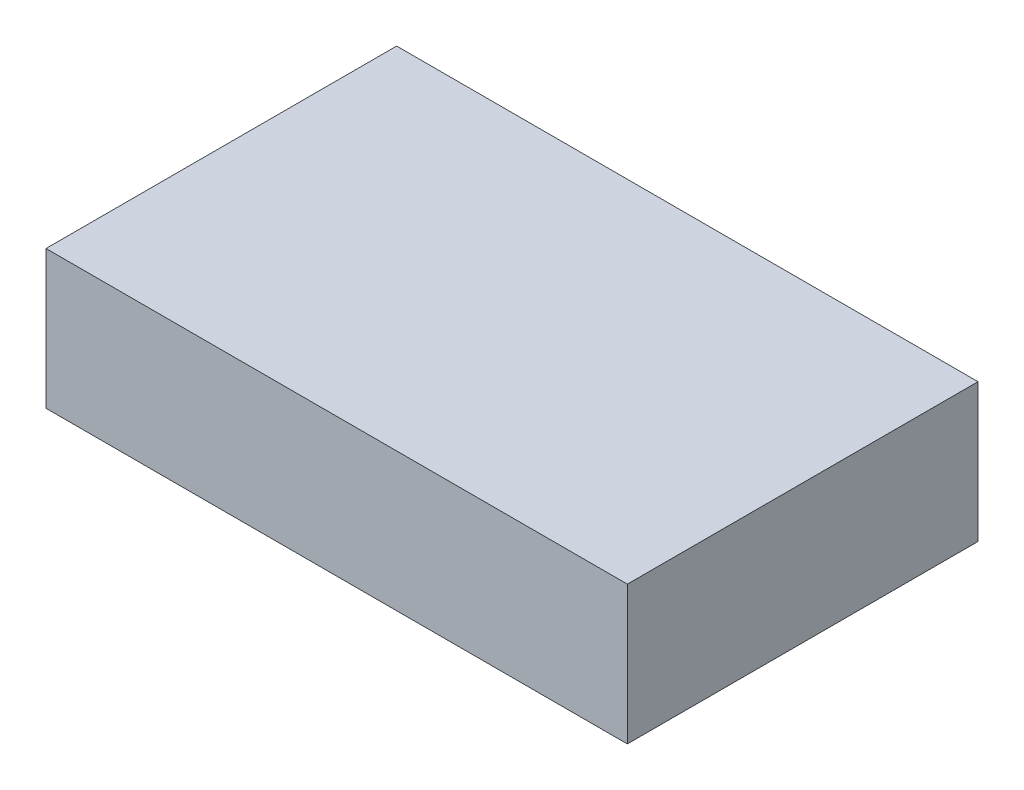
from build123d import *

# Parameters (mm, degrees)
SKETCH1_W           = 160.02
SKETCH1_H           = 96.52
BOSS_EXTRUDE1_DEPTH = 38.1


with BuildPart() as part:
    # Sketch1 → Boss-Extrude1 (new body)
    with BuildSketch(Plane(origin=(0, 0, 0), x_dir=(1, 0, 0), z_dir=(0, 1, 0))):
        Rectangle(SKETCH1_W, SKETCH1_H)
    extrude(amount=BOSS_EXTRUDE1_DEPTH)


solid = part.part
